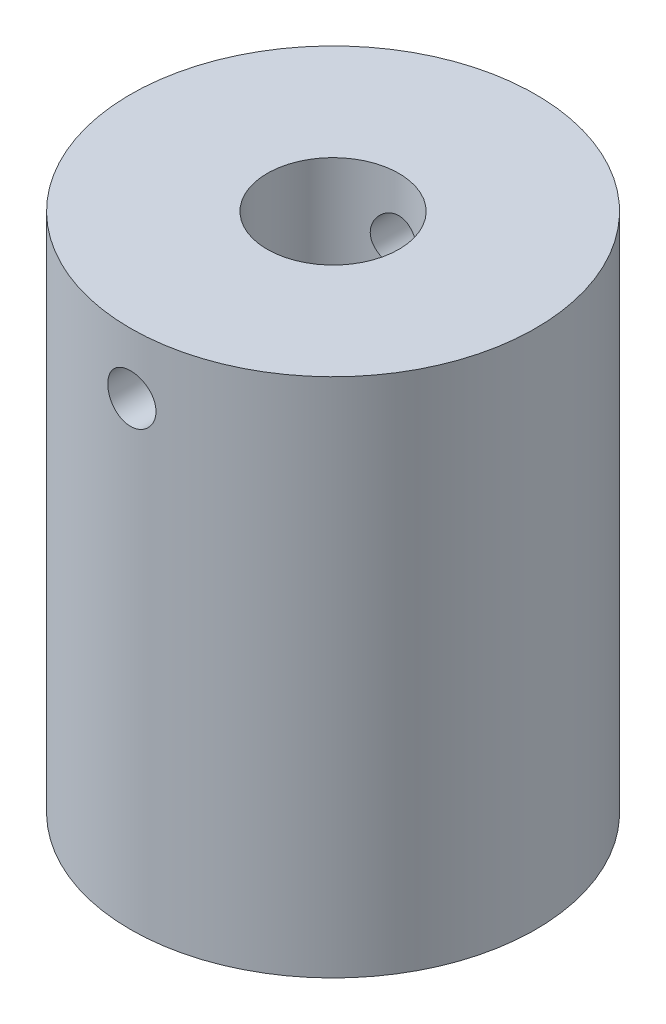
from build123d import *

# Parameters (mm, degrees)
SKETCH1_R           = 7.257142857
BOSS_EXTRUDE1_DEPTH = 18.650857143
SKETCH2_R           = 2.358571483
CUT_EXTRUDE1_DEPTH  = 5.442857143
CUT_EXTRUDE2_DEPTH  = 10.16
SKETCH4_R           = 0.8636
CUT_EXTRUDE3_DEPTH  = 15.514285714
SCALE1_SCALE        = 1.75


with BuildPart() as part:
    # Sketch1 → Boss-Extrude1 (new body)
    with BuildSketch(Plane(origin=(0, 0, 0), x_dir=(1, 0, 0), z_dir=(0, 1, 0))):
        Circle(SKETCH1_R)
    extrude(amount=BOSS_EXTRUDE1_DEPTH)

    # Sketch2 → Cut-Extrude1 (cut)
    with BuildSketch(Plane(origin=(0, 18.650857143, 0), x_dir=(1, 0, 0), z_dir=(0, 1, 0))):
        Circle(SKETCH2_R)
    extrude(amount=-CUT_EXTRUDE1_DEPTH, mode=Mode.SUBTRACT)

    # Sketch3 → Cut-Extrude2 (cut)
    with BuildSketch(Plane.XZ):
        with BuildLine():
            Line((-1.008931831, 1.9812), (1.008931831, 1.9812))
            ThreePointArc((1.008931831, 1.9812), (1.340608786, 2.22303112), (1.469422309, 1.833288937))
            ThreePointArc((1.469422309, 1.833288937), (0, -2.3495), (-1.469422309, 1.833288937))
            ThreePointArc((-1.469422309, 1.833288937), (-1.340608786, 2.22303112), (-1.008931831, 1.9812))
        make_face()
    extrude(amount=-CUT_EXTRUDE2_DEPTH, mode=Mode.SUBTRACT)

    # Sketch4 → Cut-Extrude3 (cut, through all)
    with BuildSketch(Plane.XY.offset(7.257142857)):
        with Locations((0, 16.473714177)):
            Circle(SKETCH4_R)
    extrude(amount=-CUT_EXTRUDE3_DEPTH, mode=Mode.SUBTRACT)


with BuildPart() as part_1:
    # Scale1: scaled about (-4.09e-06, 9.303254996, 0.003077039)
    add(part.part.scale(SCALE1_SCALE).moved(Location((3.067e-06, -6.977441247, -0.002307779))))


solid = part_1.part
